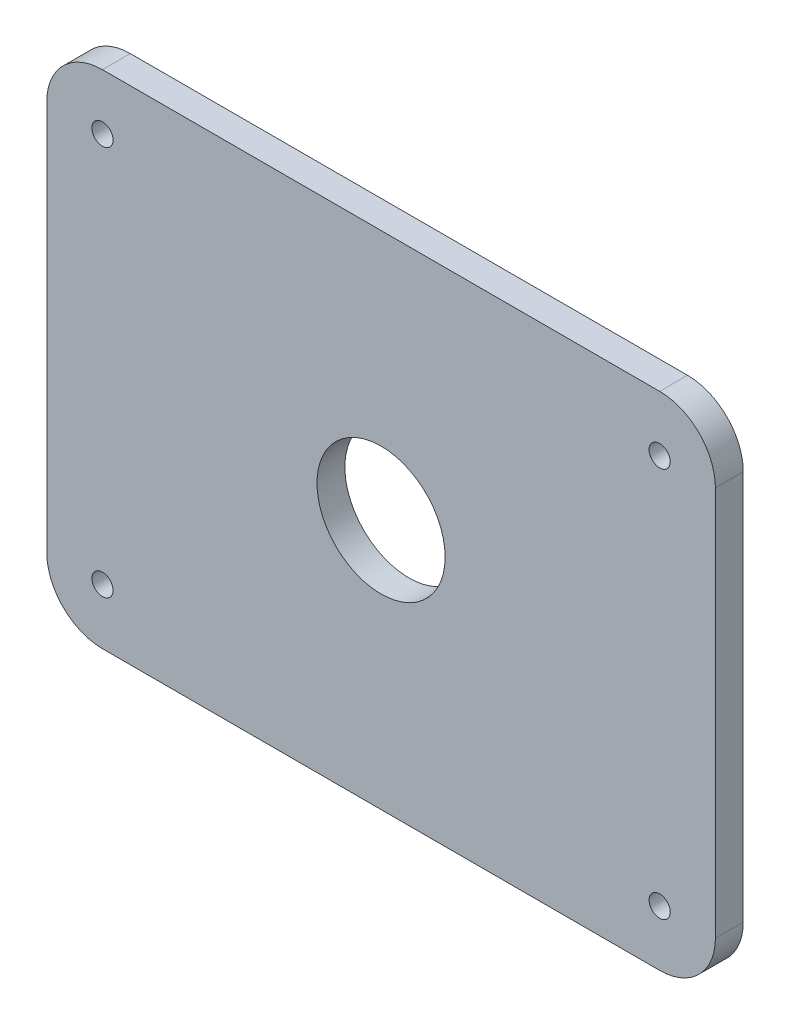
from build123d import *

# Parameters (mm, degrees)
SKETCH3_R           = 1.9
SKETCH3_R_2         = 11.5
BOSS_EXTRUDE2_DEPTH = 5


with BuildPart() as part:
    # Sketch3 → Boss-Extrude2 (new body)
    with BuildSketch(Plane.XY):
        with BuildLine():
            Line((-50, 45), (50, 45))
            ThreePointArc((50, 45), (57.071067812, 42.071067812), (60, 35))
            Line((60, 35), (60, -35))
            ThreePointArc((60, -35), (57.071067812, -42.071067812), (50, -45))
            Line((50, -45), (-50, -45))
            ThreePointArc((-50, -45), (-57.071067812, -42.071067812), (-60, -35))
            Line((-60, -35), (-60, 35))
            ThreePointArc((-60, 35), (-57.071067812, 42.071067812), (-50, 45))
        make_face()
        with Locations((-50, 35)):
            Circle(SKETCH3_R, mode=Mode.SUBTRACT)
        with Locations((50, 35)):
            Circle(SKETCH3_R, mode=Mode.SUBTRACT)
        with Locations((50, -35)):
            Circle(SKETCH3_R, mode=Mode.SUBTRACT)
        with Locations((-50, -35)):
            Circle(SKETCH3_R, mode=Mode.SUBTRACT)
        Circle(SKETCH3_R_2, mode=Mode.SUBTRACT)
    extrude(amount=BOSS_EXTRUDE2_DEPTH)


solid = part.part
